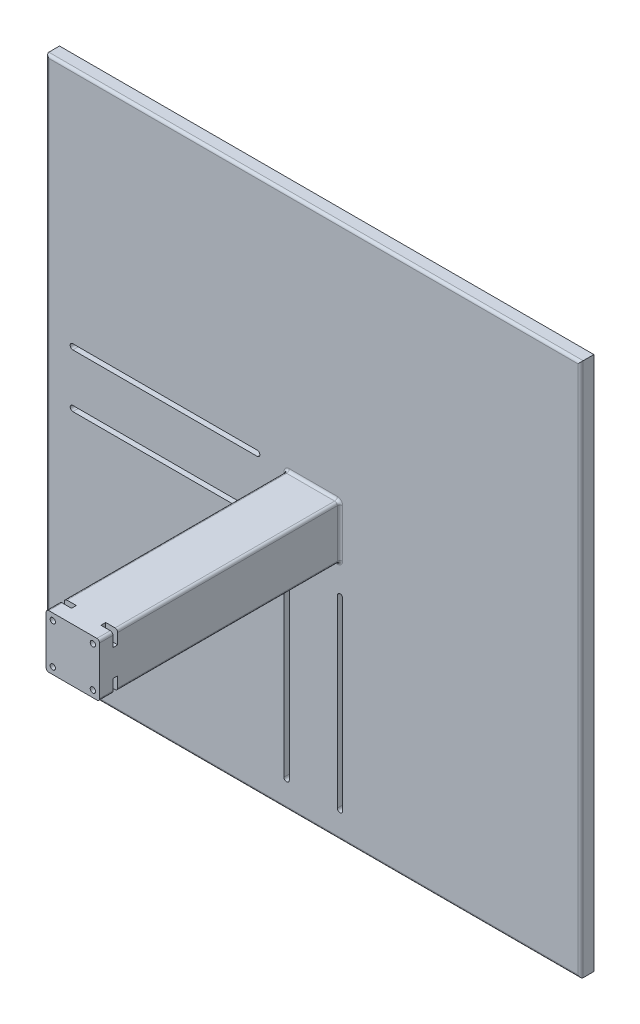
from build123d import *

# Parameters (mm, degrees)
ESQUISSE1_W             = 200
ESQUISSE1_H             = 200
BOSS_EXTRU_1_DEPTH      = 5
CONG_1_R                = 1
ESQUISSE4_W             = 20
ESQUISSE4_H             = 20
BOSS_EXTRU_4_DEPTH      = 90
CONG_3_R                = 1
ESQUISSE5_R             = 1
ENL_V_MAT_EXTRU_1_DEPTH = 5
ESQUISSE6_W             = 4.5
ESQUISSE6_H             = 1.8
ENL_V_MAT_EXTRU_2_DEPTH = 5
ENL_V_MAT_EXTRU_3_DEPTH = 6


with BuildPart() as part:
    # Esquisse1 → Boss.-Extru.1 (new body)
    with BuildSketch(Plane.XY):
        Rectangle(ESQUISSE1_W, ESQUISSE1_H)
    extrude(amount=BOSS_EXTRU_1_DEPTH)

    # Congé1
    cong_1_edges = [part.edges().sort_by_distance(p)[0] for p in [
        (100, 0, 5),
        (0, 100, 5),
        (-100, 0, 5),
        (0, -100, 5),
    ]]
    fillet(cong_1_edges, radius=CONG_1_R)

    # Esquisse4 → Boss.-Extru.4 (add)
    with BuildSketch(Plane.XY.offset(5)):
        Rectangle(ESQUISSE4_W, ESQUISSE4_H)
    extrude(amount=BOSS_EXTRU_4_DEPTH)

    # Congé3
    cong_3_edges = [part.edges().sort_by_distance(p)[0] for p in [
        (-10, 0, 5),
        (-10, 10, 50),
        (0, -10, 5),
        (-10, -10, 50),
        (10, 0, 5),
        (10, -10, 50),
        (0, 10, 5),
        (10, 10, 50),
    ]]
    fillet(cong_3_edges, radius=CONG_3_R)

    # Esquisse5 → Enlèv. mat.-Extru.1 (cut)
    with BuildSketch(Plane.XY.offset(95)):
        with Locations((7.5, 7.5)):
            Circle(ESQUISSE5_R)
        with Locations((-7.5, 7.5)):
            Circle(ESQUISSE5_R)
        with Locations((-7.5, -7.5)):
            Circle(ESQUISSE5_R)
        with Locations((7.5, -7.5)):
            Circle(ESQUISSE5_R)
    enl_v_mat_extru_1 = extrude(amount=-ENL_V_MAT_EXTRU_1_DEPTH, mode=Mode.SUBTRACT)

    # Esquisse6 → Enlèv. mat.-Extru.2 (cut)
    with BuildSketch(Plane.XZ.offset(10)):
        with Locations((-7.75, 89.1)):
            Rectangle(ESQUISSE6_W, ESQUISSE6_H)
        with Locations((7.75, 89.1)):
            Rectangle(ESQUISSE6_W, ESQUISSE6_H)
    enl_v_mat_extru_2 = extrude(amount=-ENL_V_MAT_EXTRU_2_DEPTH, mode=Mode.SUBTRACT)

    # Symétrie1: Enlèv. mat.-Extru.1, Enlèv. mat.-Extru.2 across plane
    add(enl_v_mat_extru_1.mirror(Plane.ZX), mode=Mode.SUBTRACT)
    add(enl_v_mat_extru_2.mirror(Plane.ZX), mode=Mode.SUBTRACT)

    # Esquisse7 → Enlèv. mat.-Extru.3 (cut, through all)
    with BuildSketch(Plane.XY.offset(5)):
        with BuildLine():
            Line((11, -21), (11, -90))
            ThreePointArc((11, -90), (10, -91), (9, -90))
            Line((9, -90), (9, -21))
            ThreePointArc((9, -21), (10, -20), (11, -21))
        make_face()
        with BuildLine():
            Line((-9, -21), (-9, -90))
            ThreePointArc((-9, -90), (-10, -91), (-11, -90))
            Line((-11, -90), (-11, -21))
            ThreePointArc((-11, -21), (-10, -20), (-9, -21))
        make_face()
        with BuildLine():
            Line((-21, -11), (-90, -11))
            ThreePointArc((-90, -11), (-91, -10), (-90, -9))
            Line((-90, -9), (-21, -9))
            ThreePointArc((-21, -9), (-20, -10), (-21, -11))
        make_face()
        with BuildLine():
            Line((-21, 9), (-90, 9))
            ThreePointArc((-90, 9), (-91, 10), (-90, 11))
            Line((-90, 11), (-21, 11))
            ThreePointArc((-21, 11), (-20, 10), (-21, 9))
        make_face()
    extrude(amount=-ENL_V_MAT_EXTRU_3_DEPTH, mode=Mode.SUBTRACT)


solid = part.part
